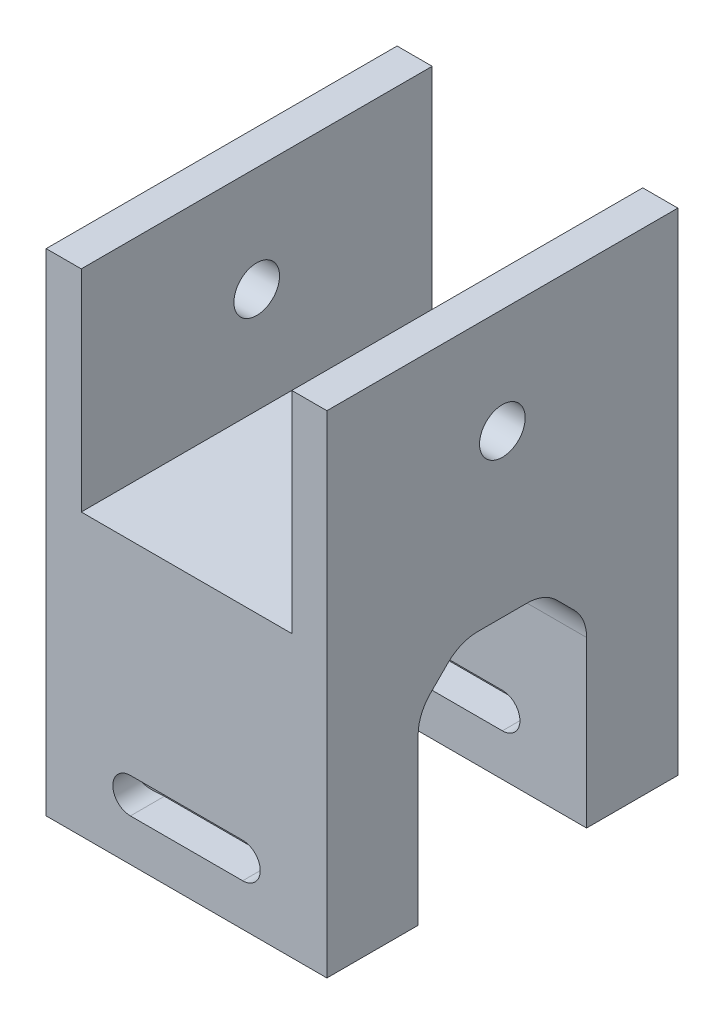
from build123d import *

# Parameters (mm, degrees)
SKETCH1_W           = 40
SKETCH1_H           = 50
BOSS_EXTRUDE1_DEPTH = 70
SKETCH2_W           = 30
SKETCH2_H           = 30
CUT_EXTRUDE1_DEPTH  = 51
SKETCH3_W           = 24
SKETCH3_H           = 32
CUT_EXTRUDE2_DEPTH  = 41
SKETCH8_R           = 3.25
CUT_EXTRUDE6_DEPTH  = 41
SKETCH5_R           = 3
CUT_EXTRUDE7_DEPTH  = 36
SKETCH9_W           = 4
SKETCH9_H           = 8
CUT_EXTRUDE8_DEPTH  = 18
CUT_EXTRUDE9_DEPTH  = 51
CHAMFER2_SIZE       = 10
CHAMFER2_SIZE2      = 21.445069205
FILLET3_R           = 40
CHAMFER4_SIZE       = 6
FILLET4_R           = 6


with BuildPart() as part:
    # Sketch1 → Boss-Extrude1 (new body)
    with BuildSketch(Plane(origin=(0, 0, 0), x_dir=(1, 0, 0), z_dir=(0, 1, 0))):
        with Locations((20, 25)):
            Rectangle(SKETCH1_W, SKETCH1_H)
    extrude(amount=BOSS_EXTRUDE1_DEPTH)

    # Sketch2 → Cut-Extrude1 (cut, through all)
    with BuildSketch(Plane.XY):
        with Locations((20, 55)):
            Rectangle(SKETCH2_W, SKETCH2_H)
    extrude(amount=-CUT_EXTRUDE1_DEPTH, mode=Mode.SUBTRACT)

    # Sketch3 → Cut-Extrude2 (cut, through all)
    with BuildSketch(Plane.ZY):
        with Locations((-25, 16)):
            Rectangle(SKETCH3_W, SKETCH3_H)
    extrude(amount=-CUT_EXTRUDE2_DEPTH, mode=Mode.SUBTRACT)

    # Sketch8 → Cut-Extrude6 (cut, through all)
    with BuildSketch(Plane.ZY):
        with Locations((-25, 55)):
            Circle(SKETCH8_R)
    extrude(amount=-CUT_EXTRUDE6_DEPTH, mode=Mode.SUBTRACT)

    # Sketch5 → Cut-Extrude7 (cut)
    with BuildSketch(Plane.ZY):
        with Locations((-43.5, 8.5)):
            Circle(SKETCH5_R)
        with Locations((-6.5, 8.5)):
            Circle(SKETCH5_R)
    extrude(amount=-CUT_EXTRUDE7_DEPTH, mode=Mode.SUBTRACT)

    # Sketch9 → Cut-Extrude8 (cut)
    with BuildSketch(Plane.XZ):
        with Locations((6, -43.5)):
            Rectangle(SKETCH9_W, SKETCH9_H)
        with Locations((6, -6.5)):
            Rectangle(SKETCH9_W, SKETCH9_H)
    extrude(amount=-CUT_EXTRUDE8_DEPTH, mode=Mode.SUBTRACT)

    # Sketch10 → Cut-Extrude9 (cut, through all)
    with BuildSketch(Plane.XY):
        with BuildLine():
            Line((28, 6), (12, 6))
            ThreePointArc((12, 6), (9.5, 8.5), (12, 11))
            Line((12, 11), (28, 11))
            ThreePointArc((28, 11), (30.5, 8.5), (28, 6))
        make_face()
    extrude(amount=-CUT_EXTRUDE9_DEPTH, mode=Mode.SUBTRACT)

    # Chamfer2
    chamfer2_edges = [part.edges().sort_by_distance(p)[0] for p in [
        (0, 32, -25),
    ]]
    chamfer2_side = [part.faces().sort_by_distance(p)[0] for p in [
        (0, 40.838498112, -25),
    ]]
    chamfer(chamfer2_edges, length=CHAMFER2_SIZE, length2=CHAMFER2_SIZE2, reference=chamfer2_side[0])

    # Fillet3
    fillet3_edges = [part.edges().sort_by_distance(p)[0] for p in [
        (21.445069205, 32, -25),
    ]]
    fillet(fillet3_edges, radius=FILLET3_R)

    # Chamfer4
    chamfer4_edges = [part.edges().sort_by_distance(p)[0] for p in [
        (6.704062621, 38.873844259, -13),
        (6.704062621, 38.873844259, -37),
        (21.655271153, 32.948159715, -37),
        (21.655271153, 32.948159715, -13),
        (35.156427855, 32, -37),
        (35.156427855, 32, -13),
    ]]
    chamfer(chamfer4_edges, length=CHAMFER4_SIZE)

    # Fillet4
    fillet4_edges = [part.edges().sort_by_distance(p)[0] for p in [
        (35.156427855, 26, -13),
        (20.35663347, 27.090383672, -13),
        (5.436207835, 32.844787141, -13),
        (6.704062621, 38.873844259, -31),
        (6.704062621, 38.873844259, -19),
        (21.655271153, 32.948159715, -31),
        (21.655271153, 32.948159715, -19),
        (35.156427855, 32, -31),
        (35.156427855, 32, -19),
        (35.156427855, 26, -37),
        (20.35663347, 27.090383672, -37),
        (5.436207835, 32.844787141, -37),
    ]]
    fillet(fillet4_edges, radius=FILLET4_R)


solid = part.part
